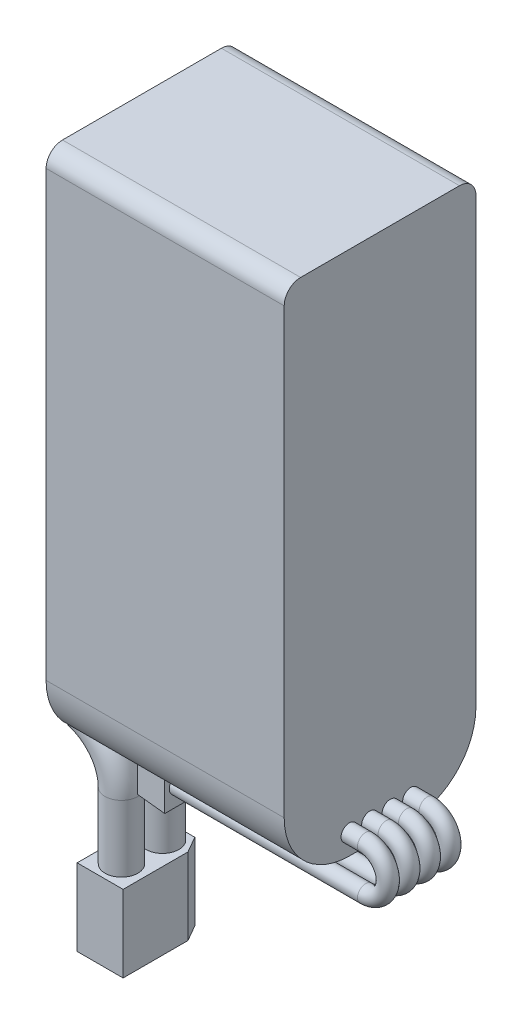
from build123d import *

# Parameters (mm, degrees)
SKETCH1_W           = 64
SKETCH1_H           = 29
BOSS_EXTRUDE1_DEPTH = 23.35
FILLET1_R           = 2
SKETCH2_R           = 2
SKETCH5_R           = 1
SKETCH7_W           = 4.6
SKETCH7_H           = 10.6
BOSS_EXTRUDE2_DEPTH = 3.5
BOSS_EXTRUDE2_TAPER = 3
BOSS_EXTRUDE3_DEPTH = 9.35
FILLET3_R           = 8


with BuildPart() as part:
    # Sketch1 → Boss-Extrude1 (new body)
    with BuildSketch(Plane(origin=(0, 0, 0), x_dir=(0, 1, 0), z_dir=(0, 0, 1))):
        Rectangle(SKETCH1_W, SKETCH1_H)
    extrude(amount=BOSS_EXTRUDE1_DEPTH)

    # Fillet1
    fillet1_edges = [part.edges().sort_by_distance(p)[0] for p in [
        (0, 32, 23.35),
        (0, 32, 0),
    ]]
    fillet(fillet1_edges, radius=FILLET1_R)

    # Sweep2: sweep along a path in Sketch4
    with BuildLine(Plane(origin=(0, 0, 0), x_dir=(0, 1, 0), z_dir=(0, 0, 1))) as sweep2_path:
        Line((-29, 14.5), (-29, 17.811482156))
        ThreePointArc((-29, 17.811482156), (-31.129819741, 20.333095361), (-33.97216907, 18.655085952))
        ThreePointArc((-33.97216907, 18.655085952), (-36.239159807, 15.640572518), (-39.83271041, 14.494739937))
        Line((-39.83271041, 14.494739937), (-47.929878258, 14.494739937))
    # Sketch2 → Sweep2 (sweep)
    with BuildSketch(Plane(origin=(-14.5, 0, 10), x_dir=(0, 0, -1), z_dir=(1, 0, 0))):
        with Locations((0.825, -29)):
            Circle(SKETCH2_R)
        with Locations((-4.175, -29)):
            Circle(SKETCH2_R)
    sweep(path=sweep2_path.line)

    # Sweep3: sweep along a path in Sketch6
    with BuildLine(Plane(origin=(0, 0, 0), x_dir=(0, 1, 0), z_dir=(0, 0, 1))) as sweep3_path:
        Line((-29.5, -14.5), (-29.5, -16.497724548))
        ThreePointArc((-29.5, -16.497724548), (-32.200025095, -19.197749643), (-34.900050191, -16.497724548))
        Line((-34.900050191, -16.497724548), (-34.900050191, 6.423160741))
    # Sketch5 → Sweep3 (sweep)
    with BuildSketch(Plane.YZ.offset(14.5)):
        with Locations((-29.5, 12.925)):
            Circle(SKETCH5_R)
        with Locations((-29.5, 10.425)):
            Circle(SKETCH5_R)
        with Locations((-29.5, 15.425)):
            Circle(SKETCH5_R)
        with Locations((-29.5, 7.925)):
            Circle(SKETCH5_R)
    sweep(path=sweep3_path.line)

    # Sketch7 → Boss-Extrude2 (add)
    with BuildSketch(Plane(origin=(-6.423160741, 0, 0), x_dir=(0, -1, 0), z_dir=(-1, 0, 0))):
        with Locations((34.900050191, 11.675)):
            Rectangle(SKETCH7_W, SKETCH7_H)
    extrude(amount=BOSS_EXTRUDE2_DEPTH, taper=BOSS_EXTRUDE2_TAPER)

    # Sketch8 → Boss-Extrude3 (add)
    with BuildSketch(Plane.XZ.offset(47.929878258)):
        Polygon((-16.35310297, 6.911630097), (-12.828061558, 6.911630097), (-11.694739937, 8.874600725), (-11.694739937, 16.775), (-17.294739937, 16.775), (-17.294739937, 8.542593166), align=None)
    extrude(amount=BOSS_EXTRUDE3_DEPTH)

    # Fillet3
    fillet3_edges = [part.edges().sort_by_distance(p)[0] for p in [
        (0, -32, 23.35),
        (0, -32, 0),
    ]]
    fillet(fillet3_edges, radius=FILLET3_R)


solid = part.part
